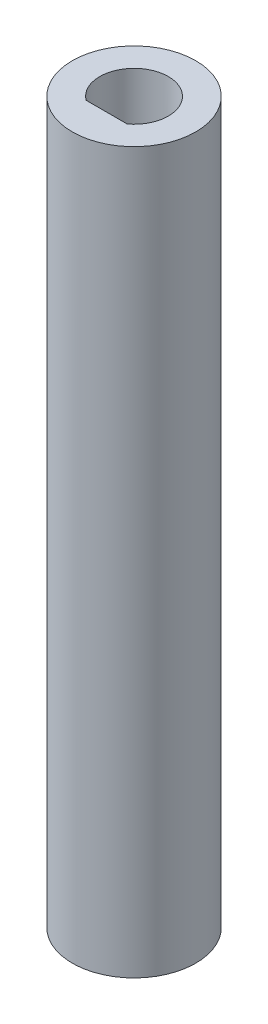
from build123d import *

# Parameters (mm, degrees)
SKETCH1_R           = 5.715
BOSS_EXTRUDE1_DEPTH = 12.7
SKETCH3_R           = 5.715
BOSS_EXTRUDE2_DEPTH = 53.975
CUT_EXTRUDE1_DEPTH  = 53.975


with BuildPart() as part:
    # Sketch1 → Boss-Extrude1 (new body)
    with BuildSketch(Plane(origin=(0, 0, 0), x_dir=(1, 0, 0), z_dir=(0, 1, 0))):
        Circle(SKETCH1_R)
        with BuildLine():
            Line((1.905, -2.54), (-1.905, -2.54))
            ThreePointArc((-1.905, -2.54), (0, 3.175), (1.905, -2.54))
        make_face(mode=Mode.SUBTRACT)
    extrude(amount=BOSS_EXTRUDE1_DEPTH)

    # Sketch3 → Boss-Extrude2 (add)
    with BuildSketch(Plane(origin=(0, 0, 0), x_dir=(-1, 0, 0), z_dir=(0, -1, 0))):
        Circle(SKETCH3_R)
    extrude(amount=BOSS_EXTRUDE2_DEPTH)

    # Sketch4 → Cut-Extrude1 (cut)
    with BuildSketch(Plane.XZ.offset(53.975)):
        Polygon((0, 2.54), (-1.796051224, 4.336051224), (-4.336051224, 1.796051224), (-2.54, 0), (-4.336051224, -1.796051224), (-1.796051224, -4.336051224), (0, -2.54), (1.796051224, -4.336051224), (4.336051224, -1.796051224), (2.54, 0), (4.336051224, 1.796051224), (1.796051224, 4.336051224), align=None)
    extrude(amount=-CUT_EXTRUDE1_DEPTH, mode=Mode.SUBTRACT)


solid = part.part
